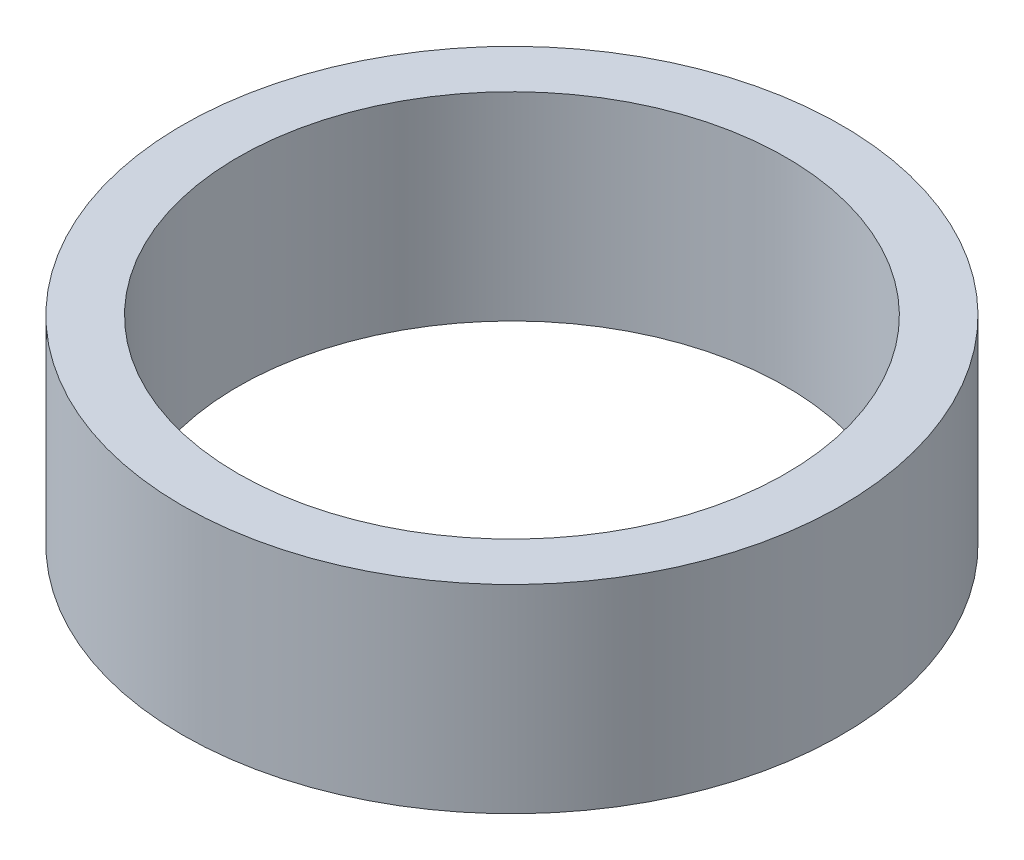
from build123d import *

# Parameters (mm, degrees)
SKETCH1_R           = 21.082
SKETCH1_R_2         = 17.526
BOSS_EXTRUDE1_DEPTH = 12.7


with BuildPart() as part:
    # Sketch1 → Boss-Extrude1 (new body)
    with BuildSketch(Plane(origin=(0, 0, 0), x_dir=(1, 0, 0), z_dir=(0, 1, 0))):
        Circle(SKETCH1_R)
        Circle(SKETCH1_R_2, mode=Mode.SUBTRACT)
    extrude(amount=BOSS_EXTRUDE1_DEPTH)


solid = part.part
